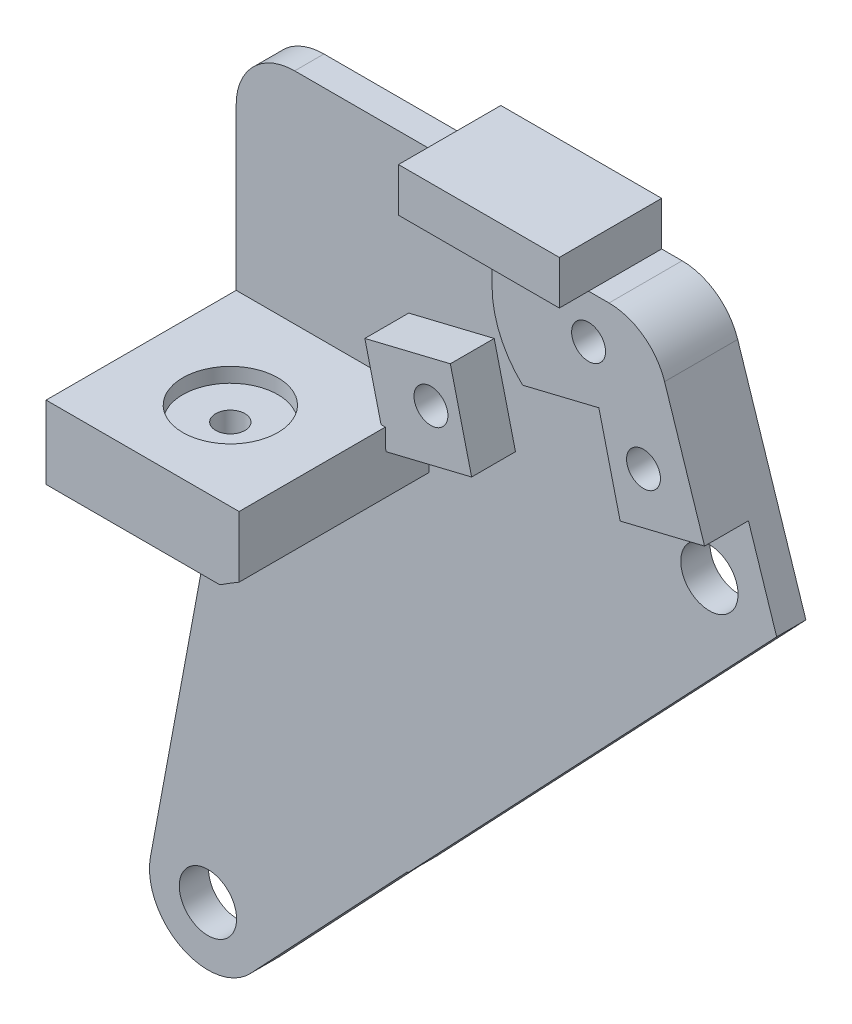
from build123d import *

# Parameters (mm, degrees)
SKETCH2_R                = 3.81
BOSS_EXTRUDE1_DEPTH      = 2.54
SKETCH5_W                = 16.764
SKETCH5_H                = 6.35
BOSS_EXTRUDE2_DEPTH      = 16.51
SKETCH6_R                = 4.1275
CUT_EXTRUDE2_DEPTH       = 1.27
SKETCH7_R                = 1.27
CUT_EXTRUDE3_DEPTH       = 65.77
CUT_EXTRUDE4_DEPTH       = 2.286
BOSS_EXTRUDE3_DEPTH      = 3.81
F_4_CLEARANCE_HOLE1_D    = 2.9464
SKETCH14_W               = 13.97
SKETCH14_H               = 3.81
BOSS_EXTRUDE6_DEPTH      = 6.35
BOSS_EXTRUDE6_DEPTH_BACK = 2.54
FILLET1_R                = 5.08
CUT_EXTRUDE5_DEPTH       = 17.51
CUT_EXTRUDE5_DEPTH_BACK  = 3.54
SKETCH19_R               = 2.4892
BOSS_EXTRUDE8_DEPTH      = 2.54
CUT_EXTRUDE8_DEPTH       = 2.54


with BuildPart() as part:
    # Sketch2 → Boss-Extrude1 (new body)
    with BuildSketch(Plane.XY):
        with BuildLine():
            Line((-17.068825413, -8.459178389), (-41.402, 40.64))
            Line((-41.402, 40.64), (-41.402, 66.04))
            Line((-41.402, 66.04), (-1.524, 66.04))
            Line((-1.524, 66.04), (18.109053667, 5.913093546))
            ThreePointArc((18.109053667, 5.913093546), (7.204933647, -17.634949139), (-17.068825413, -8.459178389))
        make_face()
        Circle(SKETCH2_R, mode=Mode.SUBTRACT)
    extrude(amount=BOSS_EXTRUDE1_DEPTH)

    # Sketch5 → Boss-Extrude2 (add)
    with BuildSketch(Plane.XY.offset(2.54)):
        with Locations((-33.02, 43.815)):
            Rectangle(SKETCH5_W, SKETCH5_H)
    extrude(amount=BOSS_EXTRUDE2_DEPTH)

    # Sketch6 → Cut-Extrude2 (cut)
    with BuildSketch(Plane(origin=(0, 46.99, 0), x_dir=(1, 0, 0), z_dir=(0, 1, 0))):
        with Locations((-33.02, -11.43)):
            Circle(SKETCH6_R)
    extrude(amount=-CUT_EXTRUDE2_DEPTH, mode=Mode.SUBTRACT)

    # Sketch7 → Cut-Extrude3 (cut, through all)
    with BuildSketch(Plane(origin=(0, 45.72, 0), x_dir=(1, 0, 0), z_dir=(0, 1, 0))):
        with Locations((-33.02, -11.43)):
            Circle(SKETCH7_R)
    extrude(amount=-CUT_EXTRUDE3_DEPTH, mode=Mode.SUBTRACT)

    # Sketch9 → Cut-Extrude4 (cut)
    with BuildSketch(Plane(origin=(0, 0, 0), x_dir=(-1, 0, 0), z_dir=(0, 0, -1))):
        Polygon((3.171122265, 62.23), (5.077532854, 58.928), (8.890354032, 58.928), (10.796764621, 62.23), (8.890354032, 65.532), (5.077532854, 65.532), align=None)
        Polygon((24.379877895, 49.663956202), (23.308143816, 53.323053276), (19.603405755, 54.224452874), (16.970401774, 51.466755398), (18.042135853, 47.807658324), (21.746873914, 46.906258726), align=None)
        Polygon((5.918476139, 54.15579827), (4.846742059, 57.814895344), (1.142003999, 58.716294942), (-1.490999983, 55.958597466), (-0.419265903, 52.299500392), (3.285472157, 51.398100794), align=None)
    extrude(amount=-CUT_EXTRUDE4_DEPTH, mode=Mode.SUBTRACT)

    # Sketch8 → Boss-Extrude3 (add)
    with BuildSketch(Plane.XY.offset(2.54)):
        with BuildLine():
            Line((-15.367, 66.04), (-6.983943443, 66.04))
            Line((-6.983943443, 66.04), (-1.524, 66.04))
            Line((-1.524, 66.04), (3.09175139, 51.904101595))
            Line((3.09175139, 51.904101595), (-4.240438106, 50.120107003))
            Line((-4.240438106, 50.120107003), (-6.088713216, 57.716488409))
            Line((-6.088713216, 57.716488409), (-12.708473154, 56.10583501))
            ThreePointArc((-12.708473154, 56.10583501), (-14.673699407, 58.891843255), (-15.367, 62.23))
            Line((-15.367, 62.23), (-15.367, 66.04))
        make_face()
        Polygon((-17.142042414, 46.981018422), (-18.990317524, 54.577399829), (-26.415687706, 52.770733449), (-24.567412596, 45.174352043), align=None)
    extrude(amount=BOSS_EXTRUDE3_DEPTH)

    # #4 Clearance Hole1 (through all)
    with Locations(Plane.XY.offset(6.35)):
        with Locations((-6.983943443, 62.23), (-20.675139834, 50.5653558), (-2.213738078, 55.057197868)):
            Hole(F_4_CLEARANCE_HOLE1_D / 2)

    # Sketch14 → Boss-Extrude6 (add, two sides)
    with BuildSketch(Plane.XY.offset(2.54)) as boss_extrude6_sk:
        with Locations((-13.968943443, 67.945)):
            Rectangle(SKETCH14_W, SKETCH14_H)
    extrude(amount=BOSS_EXTRUDE6_DEPTH)
    extrude(boss_extrude6_sk.sketch, amount=-BOSS_EXTRUDE6_DEPTH_BACK)

    # Fillet1
    fillet1_edges = [part.edges().sort_by_distance(p)[0] for p in [
        (-41.402, 66.04, 1.27),
        (-1.524, 66.04, 3.175),
    ]]
    fillet(fillet1_edges, radius=FILLET1_R)

    # Sketch15 → Cut-Extrude5 (cut, two sides)
    with BuildSketch(Plane.XY.offset(2.54)) as cut_extrude5_sk:
        with BuildLine():
            ThreePointArc((-0.315167053, 48.411374113), (-18.310138041, 44.816284079), (-33.674369734, 34.782140486))
            ThreePointArc((-33.674369734, 34.782140486), (-33.731327517, 31.262340905), (-30.211527936, 31.205383122))
            ThreePointArc((-30.211527936, 31.205383122), (-16.427248714, 40.207684038), (-0.28275743, 43.433079608))
            ThreePointArc((-0.28275743, 43.433079608), (2.190185011, 45.938431672), (-0.315167053, 48.411374113))
        make_face()
    extrude(amount=CUT_EXTRUDE5_DEPTH, mode=Mode.SUBTRACT)
    extrude(cut_extrude5_sk.sketch, amount=-CUT_EXTRUDE5_DEPTH_BACK, mode=Mode.SUBTRACT)

    # Sketch19 → Boss-Extrude8 (add, through all)
    with BuildSketch(Plane.XY.offset(2.54)):
        with BuildLine():
            Line((5.466200245, 44.632269783), (-40.158007355, -3.769954845))
            ThreePointArc((-40.158007355, -3.769954845), (-46.15516131, -4.814733016), (-48.848797168, 0.64436424))
            Line((-48.848797168, 0.64436424), (-41.402, 40.64))
            Line((-41.402, 40.64), (3.09175139, 51.904101595))
            Line((3.09175139, 51.904101595), (5.466200245, 44.632269783))
        make_face()
        with Locations((-0.298962241, 45.92222686)):
            Circle(SKETCH19_R, mode=Mode.SUBTRACT)
        with Locations((-43.854625645, -0.285501773)):
            Circle(SKETCH19_R, mode=Mode.SUBTRACT)
    extrude(amount=-BOSS_EXTRUDE8_DEPTH)

    # Sketch20 → Cut-Extrude8 (cut)
    with BuildSketch(Plane.XY.offset(2.54)):
        Polygon((-40.158007355, -3.769954845), (10.729493517, 49.863783044), (48.07174347, 14.433588323), (-7.673080914, -44.319607422), align=None)
    extrude(amount=-CUT_EXTRUDE8_DEPTH, mode=Mode.SUBTRACT)


solid = part.part
